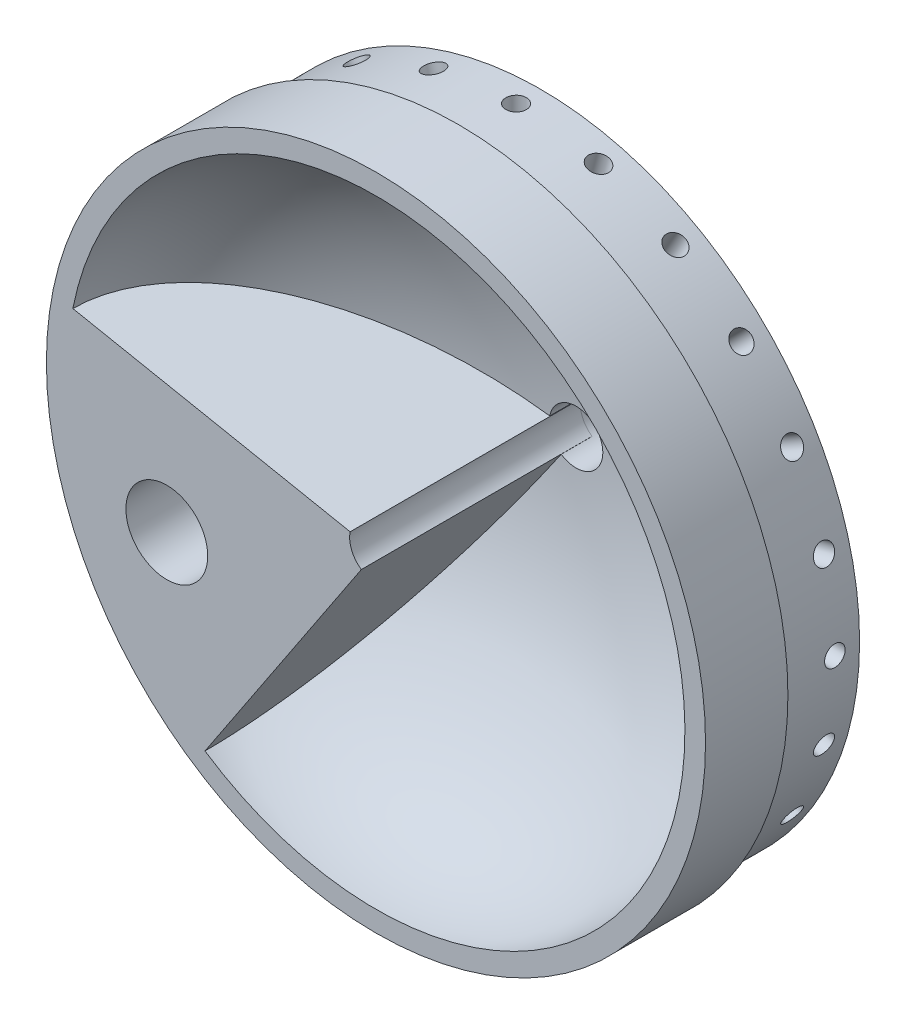
from build123d import *

# Parameters (mm, degrees)
CUT_EXTRUDE2_START      = 25.4
SKETCH3_R               = 101.6
SKETCH3_R_2             = 98.298
CUT_EXTRUDE2_DEPTH      = 138.090842223
SKETCH11_R              = 3.175
CUT_EXTRUDE3_DEPTH      = 12.7
CIRPATTERN1_COUNT       = 24
SKETCH21_R              = 12.591581597
BOSS_EXTRUDE2_DEPTH     = 71.12
CUT_EXTRUDE5_DEPTH      = 251.46
CUT_EXTRUDE5_DEPTH_BACK = 201.168
SKETCH33_R              = 8.117141655
CUT_EXTRUDE6_DEPTH      = 301.752
CUT_EXTRUDE6_DEPTH_BACK = 201.168
SKETCH34_R              = 12.612129164


with BuildPart() as part:
    # Sketch1 → Revolve1 (revolve)
    with BuildSketch(Plane(origin=(0, 0, 0), x_dir=(1, 0, 0), z_dir=(0, 1, 0))):
        with BuildLine():
            add(Edge.make_bspline(
                [(95.25, 0), (95.25, 56.760318319), (8.255, 61.679545906)],
                knots=[3.141592654, 3.141592654, 3.141592654, 4.625613452, 4.625613452, 4.625613452], degree=2, weights=[1, 0.73711148, 1]))
            Line((95.25, 0), (101.6, 0))
            Line((101.6, 0), (101.6, 50.8))
            Line((101.6, 50.8), (93.98, 50.8))
            Line((93.98, 50.8), (68.994398102, 50.8))
            Line((68.994398102, 50.8), (17.78, 75.8825))
            Line((17.78, 75.8825), (8.255, 75.8825))
            Line((8.255, 75.8825), (8.255, 61.679545906))
        make_face()
    revolve(axis=Axis((0, 0, 0), (0, 0, -1)))

    # Sketch3 → Cut-Extrude2 (cut, through all)
    with BuildSketch(Plane(origin=(0, 0, 0), x_dir=(-1, 0, 0), z_dir=(0, 0, -1)).offset(CUT_EXTRUDE2_START)):
        Circle(SKETCH3_R)
        Circle(SKETCH3_R_2, mode=Mode.SUBTRACT)
    extrude(amount=CUT_EXTRUDE2_DEPTH, mode=Mode.SUBTRACT)

    # Sketch11 → Cut-Extrude3 (cut)
    with BuildSketch(Plane(origin=(0, -98.298, 0), x_dir=(-1, 0, 0), z_dir=(0, -1, 0))):
        with Locations((0, 43.18)):
            Circle(SKETCH11_R)
    cut_extrude3 = extrude(amount=-CUT_EXTRUDE3_DEPTH, mode=Mode.SUBTRACT)

    # CirPattern1: Cut-Extrude3 ×24 about axis
    cirpattern1_axis = Axis((0, 0, 0), (0, 0, 1))
    for i in range(1, CIRPATTERN1_COUNT):
        add(cut_extrude3.rotate(cirpattern1_axis, i * 360 / CIRPATTERN1_COUNT), mode=Mode.SUBTRACT)

    # Sketch21 → Boss-Extrude2 (add)
    with BuildSketch(Plane.XY):
        with BuildLine():
            Line((0, 0), (-93.449579893, 18.431997121))
            ThreePointArc((-93.449579893, 18.431997121), (-87.923439773, -36.633744532), (-52.715538121, -79.332430573))
            Line((-52.715538121, -79.332430573), (0, 0))
        make_face()
        with Locations((-64.477189167, -26.86474599)):
            Circle(SKETCH21_R, mode=Mode.SUBTRACT)
    extrude(amount=-BOSS_EXTRUDE2_DEPTH)

    # Sketch33 → Cut-Extrude5 (cut, two sides: drawn at the far end of the back side and taken through both)
    with BuildSketch(Plane(origin=(0, 0, -53.34), x_dir=(-1, 0, 0), z_dir=(0, 0, -1)).offset(-CUT_EXTRUDE5_DEPTH_BACK)):
        Circle(SKETCH33_R)
    extrude(amount=CUT_EXTRUDE5_DEPTH + CUT_EXTRUDE5_DEPTH_BACK, mode=Mode.SUBTRACT)

    # Sketch34 → Cut-Extrude6 (cut, two sides: drawn at the far end of the back side and taken through both)
    with BuildSketch(Plane(origin=(0, 0, -53.34), x_dir=(-1, 0, 0), z_dir=(0, 0, -1)).offset(-CUT_EXTRUDE6_DEPTH_BACK)):
        with Locations((64.477189167, -26.86474599)):
            Circle(SKETCH34_R)
    extrude(amount=CUT_EXTRUDE6_DEPTH + CUT_EXTRUDE6_DEPTH_BACK, mode=Mode.SUBTRACT)


solid = part.part
